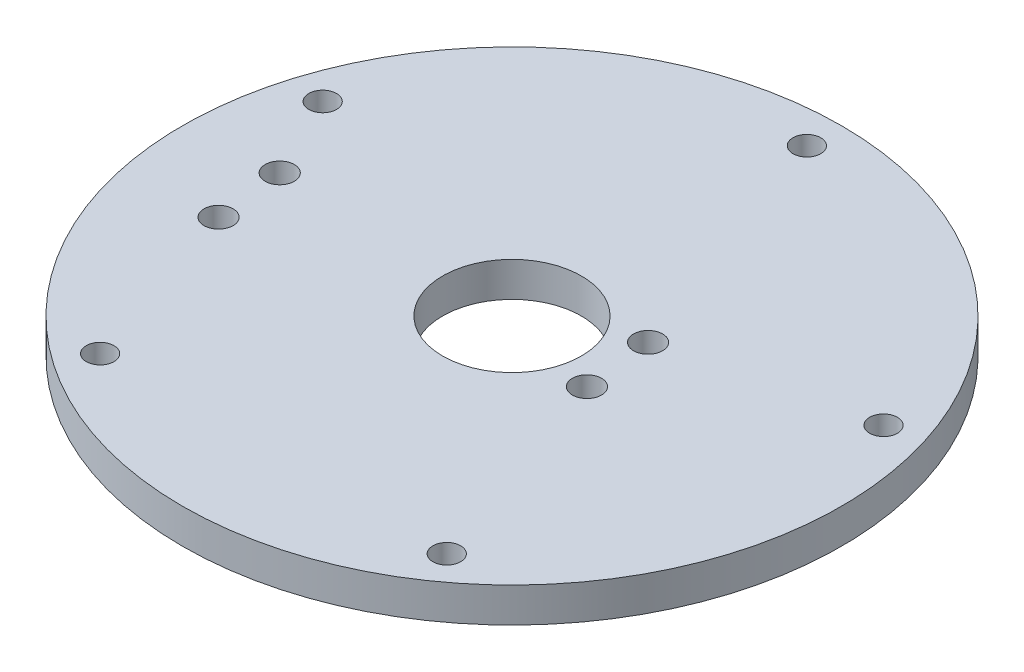
from build123d import *

# Parameters (mm, degrees)
SKETCH1_R           = 47.5
SKETCH1_R_2         = 2
SKETCH1_R_3         = 10
SKETCH1_R_4         = 2.1
BOSS_EXTRUDE1_DEPTH = 5


with BuildPart() as part:
    # Sketch1 → Boss-Extrude1 (new body)
    with BuildSketch(Plane(origin=(0, 0, 0), x_dir=(1, 0, 0), z_dir=(0, 1, 0))):
        Circle(SKETCH1_R)
        with Locations((0, 42.5)):
            Circle(SKETCH1_R_2, mode=Mode.SUBTRACT)
        with Locations((40.419901943, 13.133222261)):
            Circle(SKETCH1_R_2, mode=Mode.SUBTRACT)
        with Locations((24.980873222, -34.383222261)):
            Circle(SKETCH1_R_2, mode=Mode.SUBTRACT)
        with Locations((-24.980873222, -34.383222261)):
            Circle(SKETCH1_R_2, mode=Mode.SUBTRACT)
        with Locations((-40.419901943, 13.133222261)):
            Circle(SKETCH1_R_2, mode=Mode.SUBTRACT)
        Circle(SKETCH1_R_3, mode=Mode.SUBTRACT)
        with Locations((-34.595040144, 1.116108173)):
            Circle(SKETCH1_R_4, mode=Mode.SUBTRACT)
        with Locations((14.225114828, -3.421784349)):
            Circle(SKETCH1_R_4, mode=Mode.SUBTRACT)
        with Locations((-33.470320058, -8.820440761)):
            Circle(SKETCH1_R_4, mode=Mode.SUBTRACT)
        with Locations((13.100394742, 6.514764585)):
            Circle(SKETCH1_R_4, mode=Mode.SUBTRACT)
    extrude(amount=BOSS_EXTRUDE1_DEPTH)


solid = part.part
